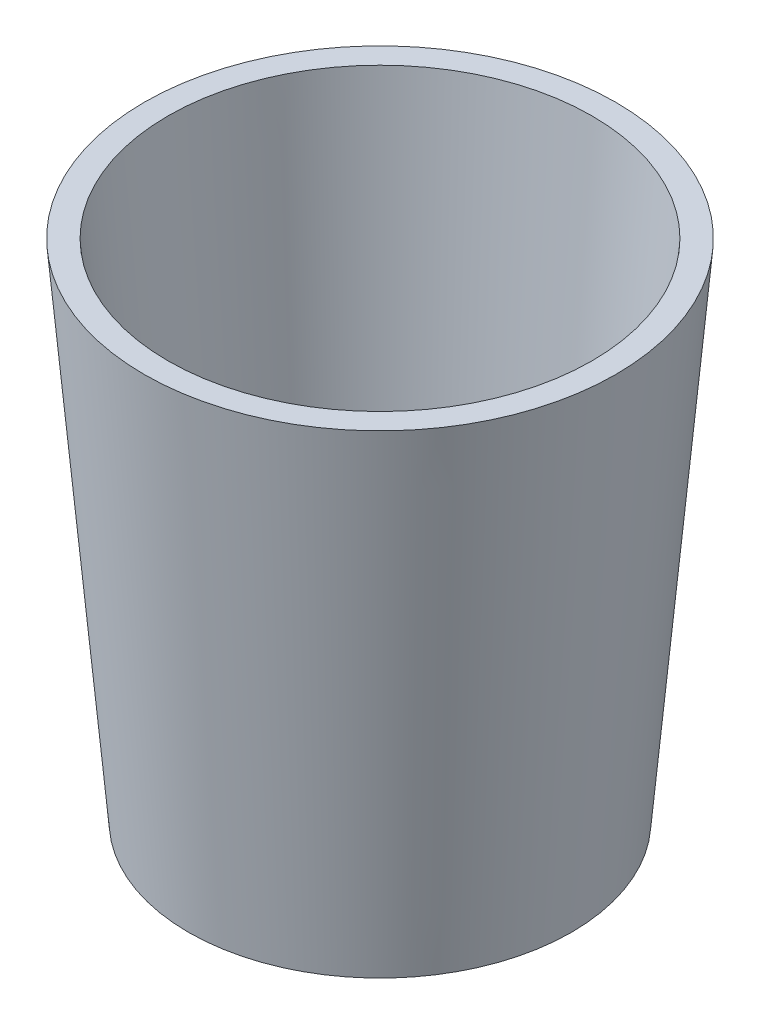
from build123d import *


with BuildPart() as part:
    # 草图2 → 旋转1 (revolve)
    with BuildSketch(Plane(origin=(0, 0, 0), x_dir=(0, 0, -1), z_dir=(1, 0, 0))):
        Polygon((-13.123299529, 150), (0, 0), (56.876700471, 0), (56.876700471, 20), (5.276965592, 20), (-6.096560666, 150), align=None)
    revolve(axis=Axis((0, 0, -56.876700471), (0, 1, 0)))


solid = part.part
